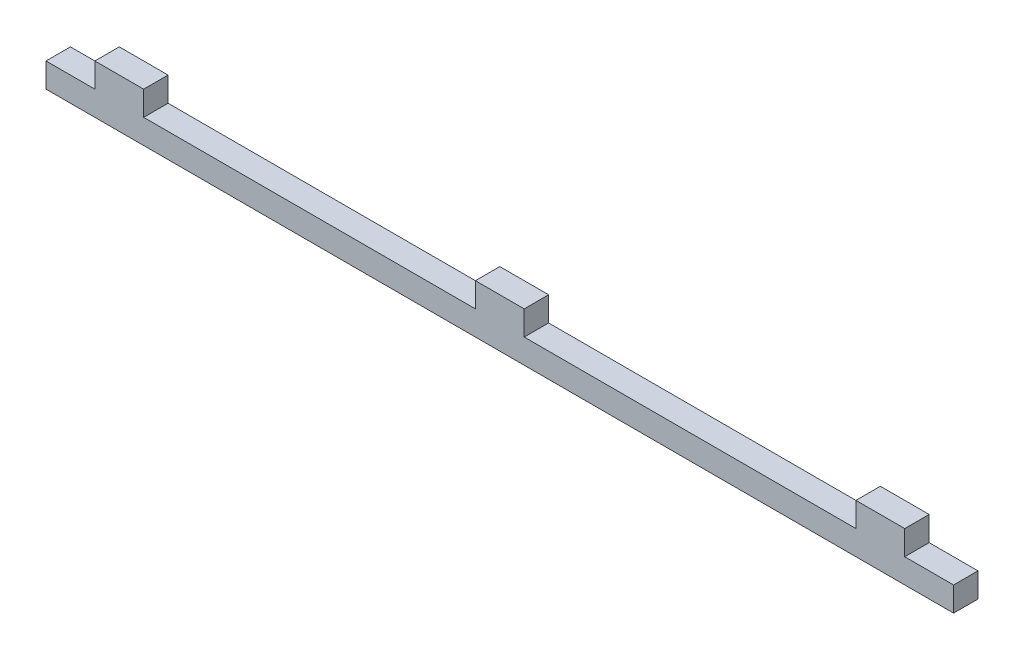
from build123d import *

# Parameters (mm, degrees)
SKETCH1_W           = 12
SKETCH1_H           = 6
SKETCH1_W_2         = 223
BOSS_EXTRUDE1_DEPTH = 6


with BuildPart() as part:
    # Sketch1 → Boss-Extrude1 (new body)
    with BuildSketch(Plane.XY):
        with Locations((-93.5, 6)):
            Rectangle(SKETCH1_W, SKETCH1_H)
        Rectangle(SKETCH1_W_2, SKETCH1_H)
        with Locations((0, 6)):
            Rectangle(SKETCH1_W, SKETCH1_H)
        with Locations((93.5, 6)):
            Rectangle(SKETCH1_W, SKETCH1_H)
    extrude(amount=-BOSS_EXTRUDE1_DEPTH)


solid = part.part
